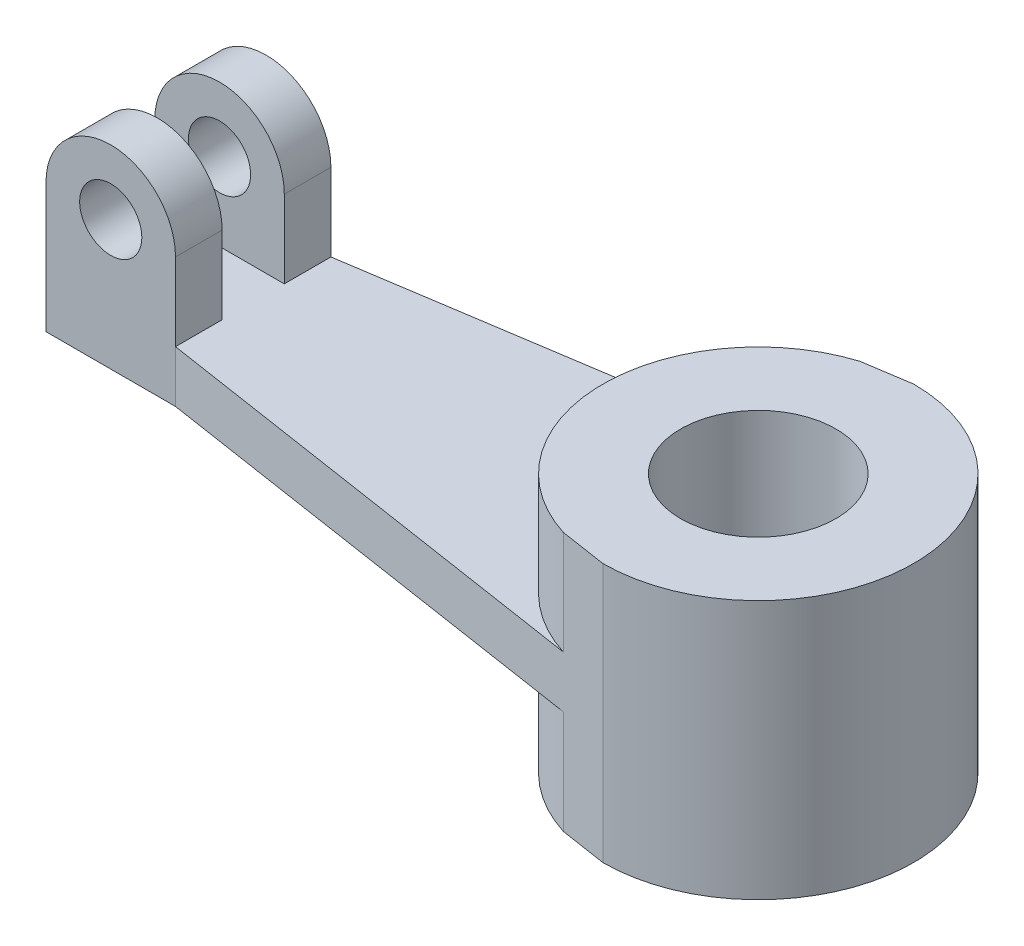
from build123d import *

# Parameters (mm, degrees)
BOSS_EXTRUDE2_DEPTH      = 10
BOSS_EXTRUDE3_DEPTH      = 20
BOSS_EXTRUDE3_DEPTH_BACK = 30
SKETCH4_R                = 15
CUT_EXTRUDE1_DEPTH       = 51
SKETCH5_W                = 25
SKETCH5_H                = 9
BOSS_EXTRUDE4_DEPTH      = 15
BOSS_EXTRUDE5_DEPTH      = 9
BOSS_EXTRUDE6_DEPTH      = 9
SKETCH8_R                = 6
CUT_EXTRUDE2_DEPTH       = 46


with BuildPart() as part:
    # Sketch1 → Boss-Extrude2 (new body)
    with BuildSketch(Plane(origin=(0, 0, 0), x_dir=(1, 0, 0), z_dir=(0, 1, 0))):
        with BuildLine():
            Line((-9.01734104, 28.612716763), (-97.5, 15))
            Line((-97.5, 15), (-122.5, 15))
            Line((-122.5, 15), (-122.5, -15))
            Line((-122.5, -15), (-97.5, -15))
            Line((-97.5, -15), (-9.01734104, -28.612716763))
            ThreePointArc((-9.01734104, -28.612716763), (-30, 0), (-9.01734104, 28.612716763))
        make_face()
        with BuildLine():
            Line((0, 30), (-9.01734104, 28.612716763))
            ThreePointArc((-9.01734104, 28.612716763), (-30, 0), (-9.01734104, -28.612716763))
            Line((-9.01734104, -28.612716763), (0, -30))
            ThreePointArc((0, -30), (21.213203436, -21.213203436), (30, 0))
            ThreePointArc((30, 0), (21.213203436, 21.213203436), (0, 30))
        make_face()
    extrude(amount=BOSS_EXTRUDE2_DEPTH)

    # Sketch3 → Boss-Extrude3 (add, two sides)
    with BuildSketch(Plane(origin=(0, 10, 0), x_dir=(1, 0, 0), z_dir=(0, 1, 0))) as boss_extrude3_sk:
        with BuildLine():
            Line((0, 30), (-9.01734104, 28.612716763))
            ThreePointArc((-9.01734104, 28.612716763), (-30, 0), (-9.01734104, -28.612716763))
            Line((-9.01734104, -28.612716763), (0, -30))
            ThreePointArc((0, -30), (21.213203436, -21.213203436), (30, 0))
            ThreePointArc((30, 0), (21.213203436, 21.213203436), (0, 30))
        make_face()
    extrude(amount=BOSS_EXTRUDE3_DEPTH)
    extrude(boss_extrude3_sk.sketch, amount=-BOSS_EXTRUDE3_DEPTH_BACK)

    # Sketch4 → Cut-Extrude1 (cut, through all)
    with BuildSketch(Plane(origin=(0, 30, 0), x_dir=(1, 0, 0), z_dir=(0, 1, 0))):
        Circle(SKETCH4_R)
    extrude(amount=-CUT_EXTRUDE1_DEPTH, mode=Mode.SUBTRACT)

    # Sketch5 → Boss-Extrude4 (add)
    with BuildSketch(Plane(origin=(0, 10, 0), x_dir=(1, 0, 0), z_dir=(0, 1, 0))):
        with Locations((-110, 10.5)):
            Rectangle(SKETCH5_W, SKETCH5_H)
        with Locations((-110, -10.5)):
            Rectangle(SKETCH5_W, SKETCH5_H)
    extrude(amount=BOSS_EXTRUDE4_DEPTH)

    # Sketch6 → Boss-Extrude5 (add)
    with BuildSketch(Plane.XY.offset(15)):
        with BuildLine():
            ThreePointArc((-122.5, 25), (-110, 37.5), (-97.5, 25))
            Line((-97.5, 25), (-122.5, 25))
        make_face()
    extrude(amount=-BOSS_EXTRUDE5_DEPTH)

    # Sketch7 → Boss-Extrude6 (add)
    with BuildSketch(Plane(origin=(0, 0, -15), x_dir=(-1, 0, 0), z_dir=(0, 0, -1))):
        with BuildLine():
            Line((97.5, 25), (122.5, 25))
            ThreePointArc((122.5, 25), (110, 37.5), (97.5, 25))
        make_face()
    extrude(amount=-BOSS_EXTRUDE6_DEPTH)

    # Sketch8 → Cut-Extrude2 (cut, through all)
    with BuildSketch(Plane.XY.offset(15)):
        with Locations((-110, 25)):
            Circle(SKETCH8_R)
    extrude(amount=-CUT_EXTRUDE2_DEPTH, mode=Mode.SUBTRACT)


solid = part.part
